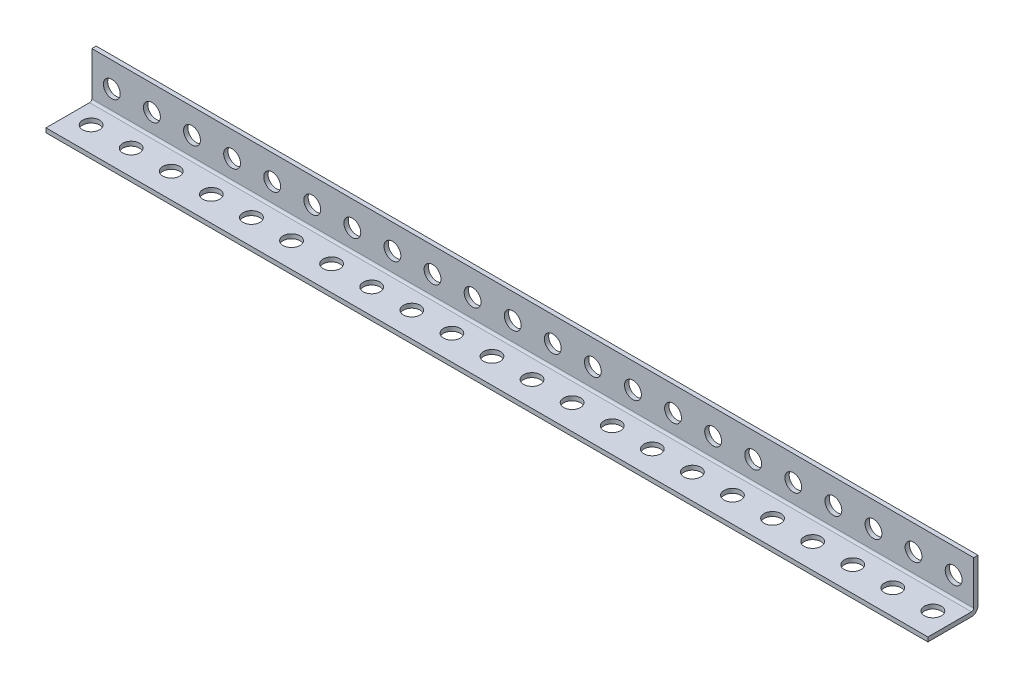
from build123d import *

# Parameters (mm, degrees)
BOSS_EXTRUDE1_DEPTH      = 609.6
BOSS_EXTRUDE1_DEPTH_BACK = 609.6
SKETCH5_R                = 5.334
CUT_EXTRUDE1_DEPTH       = 16.875
SKETCH6_R                = 5.334
CUT_EXTRUDE2_DEPTH       = 16.875
LPATTERN1_COUNT          = 48
LPATTERN1_PITCH          = 25.4
SKETCH7_W                = 635
SKETCH7_H                = 31.75
CUT_EXTRUDE3_DEPTH       = 70
SKETCH8_R                = 5.334
SKETCH8_W                = 25.4
SKETCH8_H                = 4.1148
CUT_EXTRUDE4_DEPTH       = 70


with BuildPart() as part:
    # Sketch4 → Boss-Extrude1 (new body, two sides)
    with BuildSketch(Plane(origin=(0, 0, 0), x_dir=(0, 0, -1), z_dir=(1, 0, 0))) as boss_extrude1_sk:
        with BuildLine():
            Line((-15.875, -13.1318), (11.7602, -13.1318))
            ThreePointArc((11.7602, -13.1318), (12.730067661, -12.730067661), (13.1318, -11.7602))
            Line((13.1318, -11.7602), (13.1318, 15.875))
            Line((13.1318, 15.875), (15.875, 15.875))
            Line((15.875, 15.875), (15.875, -11.7602))
            ThreePointArc((15.875, -11.7602), (14.669802983, -14.669802983), (11.7602, -15.875))
            Line((11.7602, -15.875), (-15.875, -15.875))
            Line((-15.875, -15.875), (-15.875, -13.1318))
        make_face()
    extrude(amount=BOSS_EXTRUDE1_DEPTH)
    extrude(boss_extrude1_sk.sketch, amount=-BOSS_EXTRUDE1_DEPTH_BACK)

    # Sketch5 → Cut-Extrude1 (cut, through all)
    with BuildSketch(Plane.XY):
        with Locations((596.9, 0)):
            Circle(SKETCH5_R)
    cut_extrude1 = extrude(amount=-CUT_EXTRUDE1_DEPTH, mode=Mode.SUBTRACT)

    # Sketch6 → Cut-Extrude2 (cut, through all)
    with BuildSketch(Plane(origin=(0, 0, 0), x_dir=(1, 0, 0), z_dir=(0, 1, 0))):
        with Locations((596.9, 0)):
            Circle(SKETCH6_R)
    cut_extrude2 = extrude(amount=-CUT_EXTRUDE2_DEPTH, mode=Mode.SUBTRACT)

    # LPattern1: Cut-Extrude1, Cut-Extrude2 ×48
    with Locations(*[(-i * LPATTERN1_PITCH, 0, 0) for i in range(1, LPATTERN1_COUNT)]):
        add(cut_extrude1, mode=Mode.SUBTRACT)
        add(cut_extrude2, mode=Mode.SUBTRACT)

    # Sketch7 → Cut-Extrude3 (cut)
    with BuildSketch(Plane(origin=(0, 0, -15.875), x_dir=(-1, 0, 0), z_dir=(0, 0, -1))):
        with Locations((-292.1, 0)):
            Rectangle(SKETCH7_W, SKETCH7_H)
    extrude(amount=-CUT_EXTRUDE3_DEPTH, mode=Mode.SUBTRACT)

    # Sketch8 → Cut-Extrude4 (cut)
    with BuildSketch(Plane(origin=(0, 0, -15.875), x_dir=(-1, 0, 0), z_dir=(0, 0, -1))):
        Polygon((50.8, 15.875), (25.4, 15.875), (25.4, -11.7602), (50.8, -11.7602), (50.8, 0), align=None)
        with Locations((38.1, 0)):
            Circle(SKETCH8_R, mode=Mode.SUBTRACT)
        with Locations((38.1, -13.8176)):
            Rectangle(SKETCH8_W, SKETCH8_H)
    extrude(amount=-CUT_EXTRUDE4_DEPTH, mode=Mode.SUBTRACT)


solid = part.part
